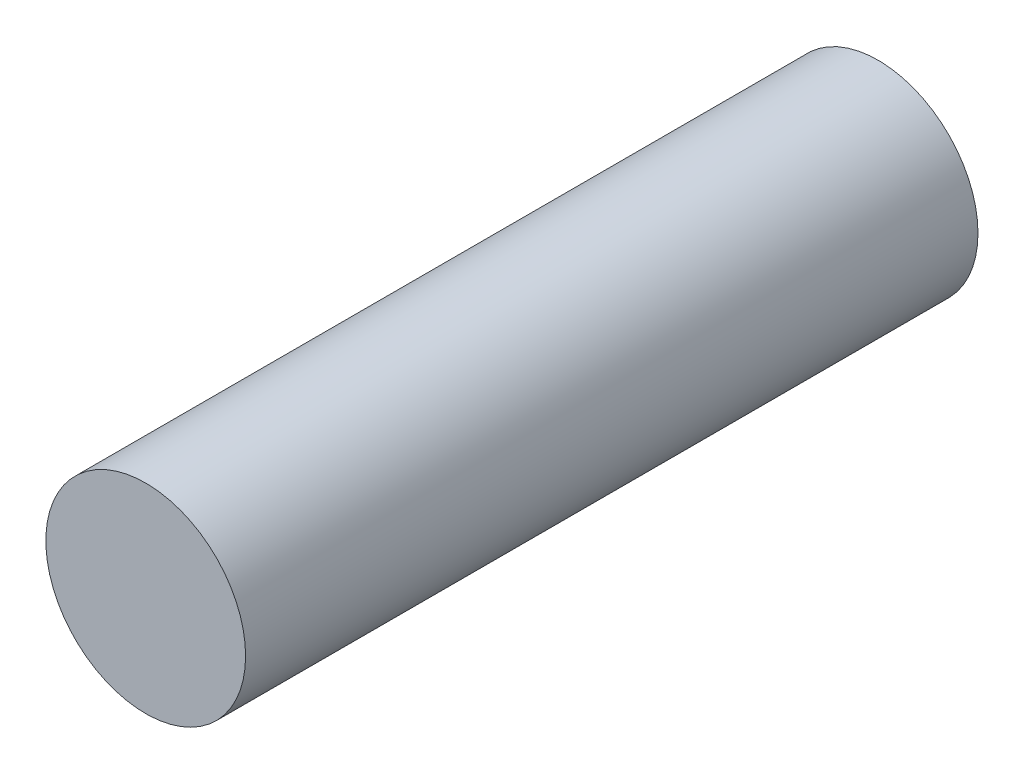
from build123d import *

# Parameters (mm, degrees)
SKETCH1_R           = 9.525
BOSS_EXTRUDE1_DEPTH = 69.85


with BuildPart() as part:
    # Sketch1 → Boss-Extrude1 (new body)
    with BuildSketch(Plane.XY):
        Circle(SKETCH1_R)
    extrude(amount=BOSS_EXTRUDE1_DEPTH)


solid = part.part
